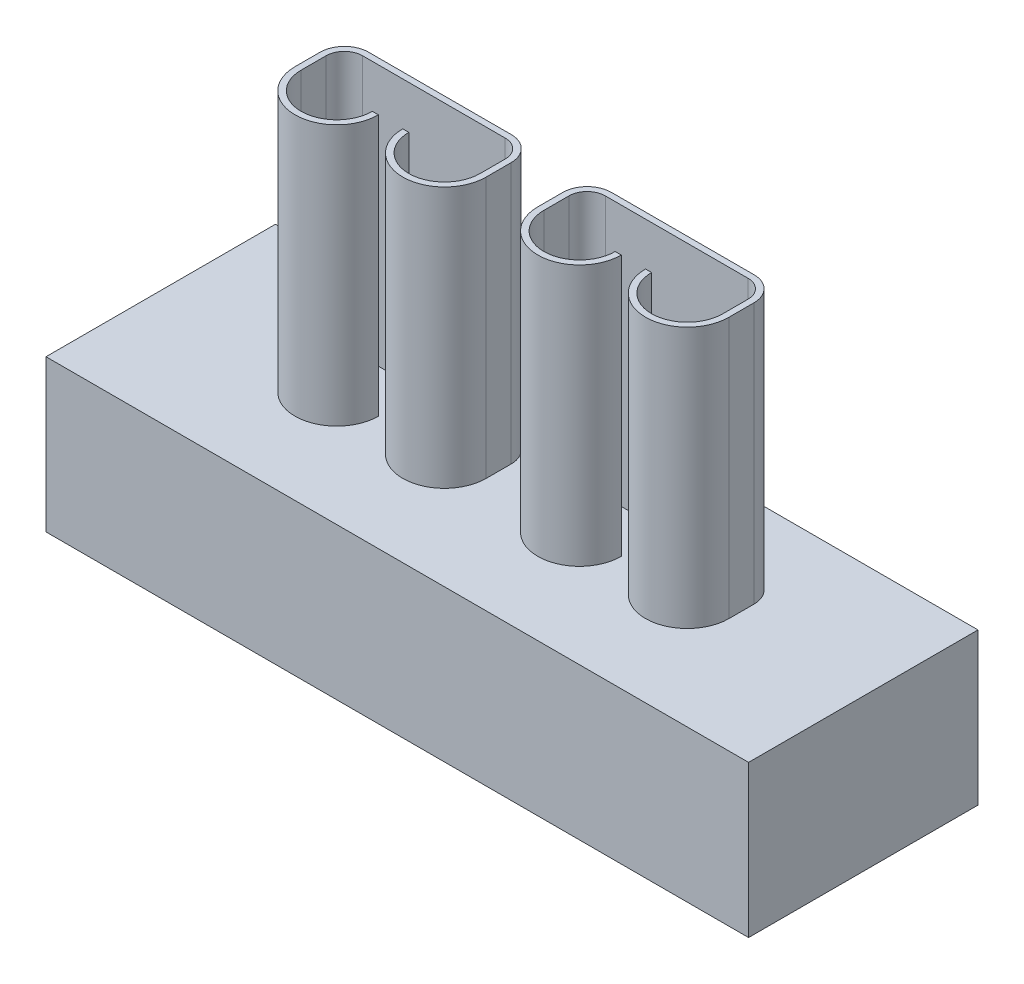
from build123d import *

# Parameters (mm, degrees)
SKETCH1_W           = 14.7
SKETCH1_H           = 4.8
BOSS_EXTRUDE1_DEPTH = 3.175
BOSS_EXTRUDE2_DEPTH = 5.461


with BuildPart() as part:
    # Sketch1 → Boss-Extrude1 (new body)
    with BuildSketch(Plane(origin=(0, 0, 0), x_dir=(1, 0, 0), z_dir=(0, 1, 0))):
        Rectangle(SKETCH1_W, SKETCH1_H)
    extrude(amount=BOSS_EXTRUDE1_DEPTH)

    # Sketch2 → Boss-Extrude2 (add)
    with BuildSketch(Plane(origin=(0, 3.175, 0), x_dir=(1, 0, 0), z_dir=(0, 1, 0))):
        with BuildLine():
            Line((-4.032, 1.032), (-1.048, 1.032))
            ThreePointArc((-1.048, 1.032), (-0.688789755, 0.883210245), (-0.54, 0.524))
            Line((-0.54, 0.524), (-0.54, 0))
            ThreePointArc((-0.54, 0), (-1.413, -0.873), (-2.286, 0))
            Line((-2.286, 0), (-2.159, 0))
            ThreePointArc((-2.159, 0), (-1.413, -0.746), (-0.667, 0))
            Line((-0.667, 0), (-0.667, 0.524))
            ThreePointArc((-0.667, 0.524), (-0.778592316, 0.793407684), (-1.048, 0.905))
            Line((-1.048, 0.905), (-4.032, 0.905))
            ThreePointArc((-4.032, 0.905), (-4.301407684, 0.793407684), (-4.413, 0.524))
            Line((-4.413, 0.524), (-4.413, 0))
            ThreePointArc((-4.413, 0), (-3.667, -0.746), (-2.921, 0))
            Line((-2.921, 0), (-2.794, 0))
            ThreePointArc((-2.794, 0), (-3.667, -0.873), (-4.54, 0))
            Line((-4.54, 0), (-4.54, 0.524))
            ThreePointArc((-4.54, 0.524), (-4.391210245, 0.883210245), (-4.032, 1.032))
        make_face()
        with BuildLine():
            Line((4.54, 0.524), (4.54, 0))
            ThreePointArc((4.54, 0), (3.667, -0.873), (2.794, 0))
            Line((2.794, 0), (2.921, 0))
            ThreePointArc((2.921, 0), (3.667, -0.746), (4.413, 0))
            Line((4.413, 0), (4.413, 0.524))
            ThreePointArc((4.413, 0.524), (4.301407684, 0.793407684), (4.032, 0.905))
            Line((4.032, 0.905), (1.048, 0.905))
            ThreePointArc((1.048, 0.905), (0.778592316, 0.793407684), (0.667, 0.524))
            Line((0.667, 0.524), (0.667, 0))
            ThreePointArc((0.667, 0), (1.413, -0.746), (2.159, 0))
            Line((2.159, 0), (2.286, 0))
            ThreePointArc((2.286, 0), (1.413, -0.873), (0.54, 0))
            Line((0.54, 0), (0.54, 0.524))
            ThreePointArc((0.54, 0.524), (0.688789755, 0.883210245), (1.048, 1.032))
            Line((1.048, 1.032), (4.032, 1.032))
            ThreePointArc((4.032, 1.032), (4.391210245, 0.883210245), (4.54, 0.524))
        make_face()
    extrude(amount=BOSS_EXTRUDE2_DEPTH)


solid = part.part
